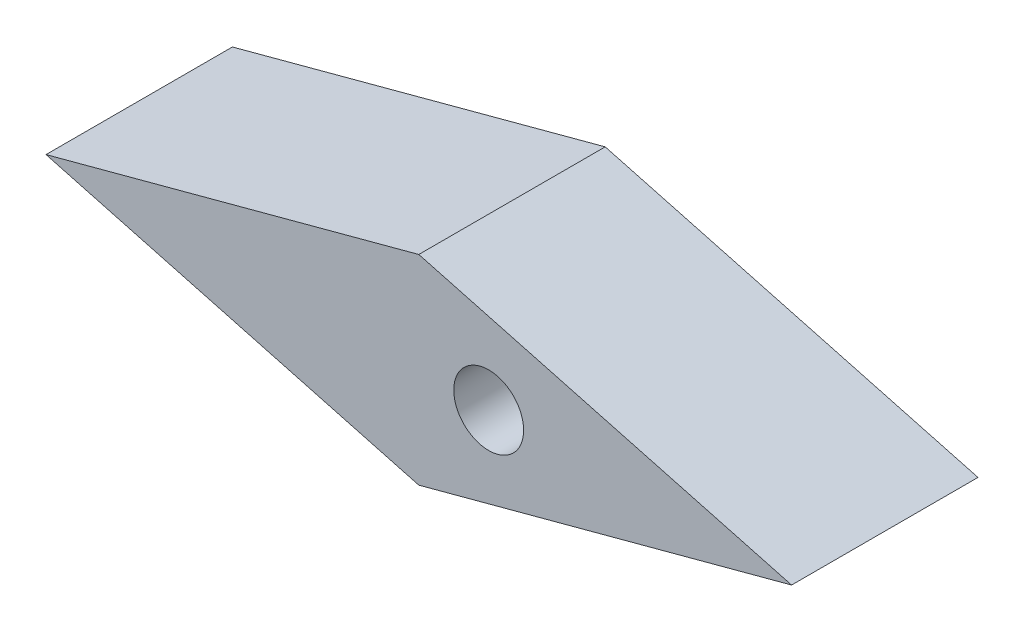
from build123d import *

# Parameters (mm, degrees)
EXTRUDE_1_DEPTH     = 8
SKETCH_2_R          = 1.5
CUT_EXTRUDE_1_DEPTH = 9
SKETCH_3_R          = 2.5
CUT_EXTRUDE_2_DEPTH = 3


with BuildPart() as part:
    # 草图1 → 凸台-拉伸1 (new body)
    with BuildSketch(Plane.XY):
        Polygon((-16, 0), (0, 4.287187079), (16, 0), (0, -4.287187079), align=None)
    extrude(amount=EXTRUDE_1_DEPTH)

    # 草图2 → 切除-拉伸1 (cut, through all)
    with BuildSketch(Plane(origin=(0, 0, 0), x_dir=(-1, 0, 0), z_dir=(0, 0, -1))):
        with Locations((-3, 0)):
            Circle(SKETCH_2_R)
    extrude(amount=-CUT_EXTRUDE_1_DEPTH, mode=Mode.SUBTRACT)

    # 草图3 → 切除-拉伸2 (cut)
    with BuildSketch(Plane(origin=(0, 0, 0), x_dir=(-1, 0, 0), z_dir=(0, 0, -1))):
        with Locations((-3, 0)):
            Circle(SKETCH_3_R)
    extrude(amount=-CUT_EXTRUDE_2_DEPTH, mode=Mode.SUBTRACT)


solid = part.part
